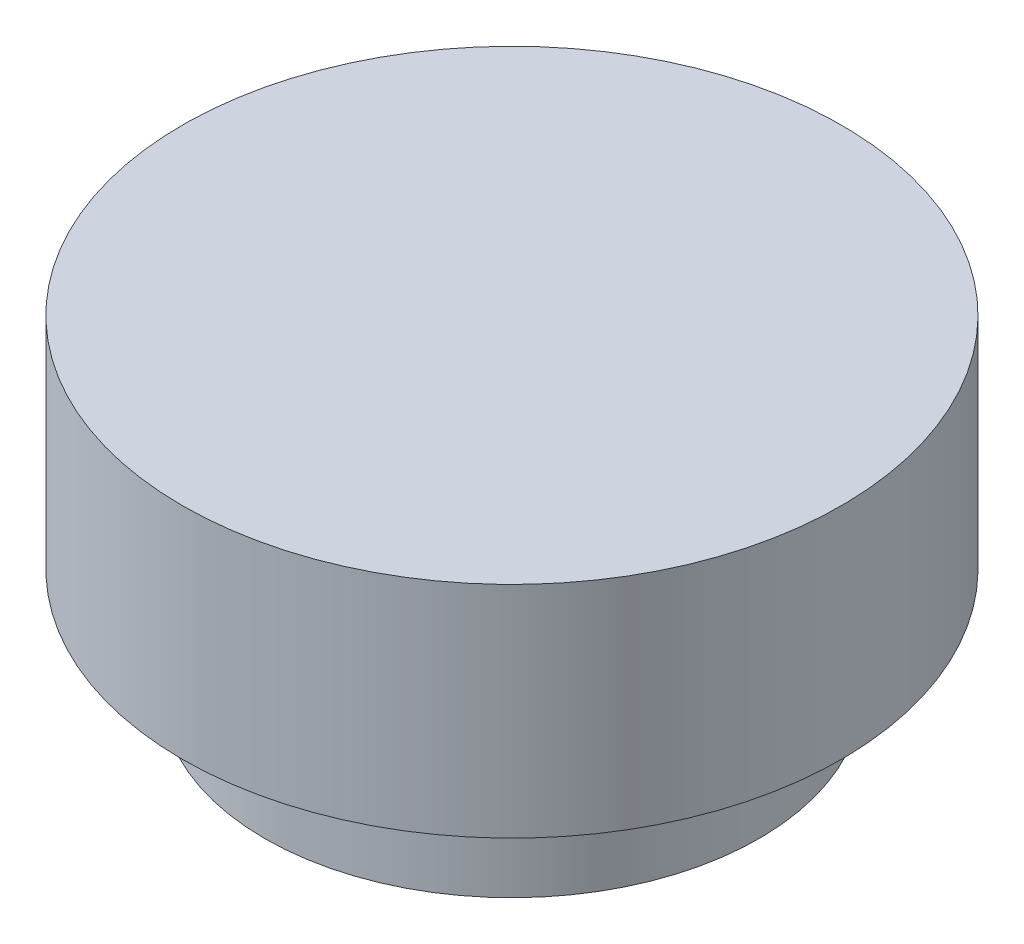
from build123d import *

# Parameters (mm, degrees)
SKETCH1_R           = 22.5
BOSS_EXTRUDE1_DEPTH = 10
SKETCH2_R           = 30
BOSS_EXTRUDE2_DEPTH = 20
SKETCH3_R           = 16.5
CUT_EXTRUDE2_DEPTH  = 5


with BuildPart() as part:
    # Sketch1 → Boss-Extrude1 (new body)
    with BuildSketch(Plane(origin=(0, 0, 0), x_dir=(1, 0, 0), z_dir=(0, 1, 0))):
        Circle(SKETCH1_R)
    extrude(amount=BOSS_EXTRUDE1_DEPTH)

    # Sketch2 → Boss-Extrude2 (add)
    with BuildSketch(Plane(origin=(0, 10, 0), x_dir=(1, 0, 0), z_dir=(0, 1, 0))):
        Circle(SKETCH2_R)
    extrude(amount=BOSS_EXTRUDE2_DEPTH)

    # Sketch3 → Cut-Extrude2 (cut)
    with BuildSketch(Plane.XZ):
        with BuildLine():
            ThreePointArc((-14.551420086, 2.778571429), (0, 11.5), (14.551420086, 2.778571429))
            Line((14.551420086, 2.778571429), (4.83856504, 20.948467447))
            ThreePointArc((4.83856504, 20.948467447), (0, 21.5), (-4.83856504, 20.948467447))
            Line((-4.83856504, 20.948467447), (-14.551420086, 2.778571429))
        make_face()
        with Locations((0, -5)):
            Circle(SKETCH3_R)
    extrude(amount=-CUT_EXTRUDE2_DEPTH, mode=Mode.SUBTRACT)


solid = part.part
